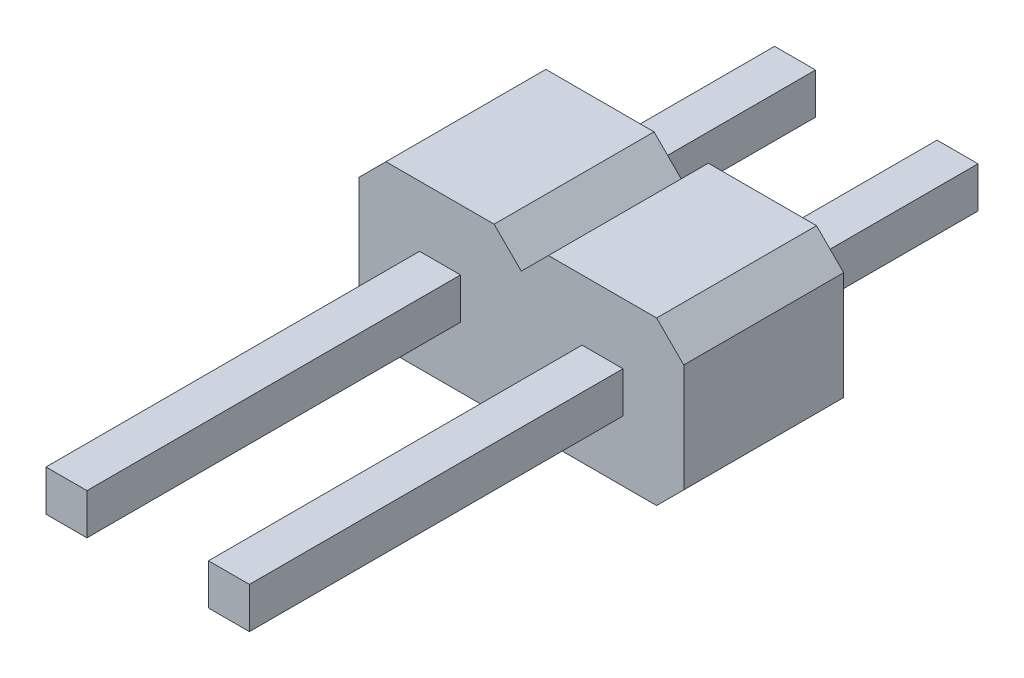
from build123d import *

# Parameters (mm, degrees)
PEG_DEPTH      = 2.5
TAIL_BASE_W    = 0.64
TAIL_BASE_H    = 0.64
TAIL_DEPTH     = 3.05
HEAD_BASE_W    = 0.64
HEAD_BASE_H    = 0.64
HEAD_DEPTH     = 5.84
MULTIPLY_COUNT = 2
MULTIPLY_PITCH = 2.54


with BuildPart() as part:
    # peg base → peg (new body)
    with BuildSketch(Plane.XY):
        Polygon((0.845735931, -1.27), (1.27, -0.845735931), (1.27, 0.845735931), (0.845735931, 1.27), (-0.845735931, 1.27), (-1.27, 0.845735931), (-1.27, -0.845735931), (-0.845735931, -1.27), align=None)
    peg = extrude(amount=PEG_DEPTH)

    # tail base → tail (add)
    with BuildSketch(Plane(origin=(0, 0, 0), x_dir=(-1, 0, 0), z_dir=(0, 0, -1))):
        Rectangle(TAIL_BASE_W, TAIL_BASE_H)
    tail = extrude(amount=TAIL_DEPTH)

    # head base → head (add)
    with BuildSketch(Plane.XY.offset(2.5)):
        Rectangle(HEAD_BASE_W, HEAD_BASE_H)
    head = extrude(amount=HEAD_DEPTH)

    # multiply: peg, tail, head ×2
    with Locations(*[(i * MULTIPLY_PITCH, 0, 0) for i in range(1, MULTIPLY_COUNT)]):
        add(peg)
        add(tail)
        add(head)


solid = part.part
